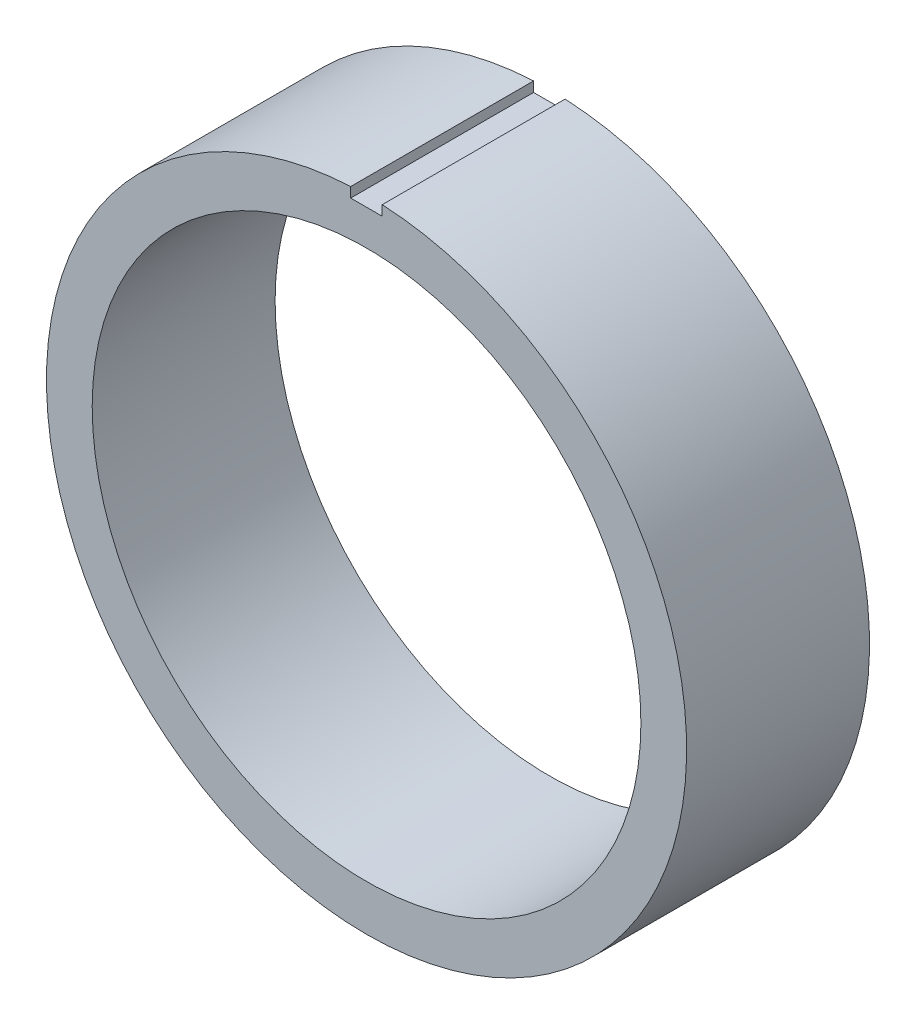
from build123d import *

# Parameters (mm, degrees)
SKETCH1_R           = 14
SKETCH1_R_2         = 12
BOSS_EXTRUDE1_DEPTH = 8
SKETCH2_W           = 1.376963526
SKETCH2_H           = 0.817572093
CUT_EXTRUDE1_DEPTH  = 10


with BuildPart() as part:
    # Sketch1 → Boss-Extrude1 (new body)
    with BuildSketch(Plane.XY):
        Circle(SKETCH1_R)
        Circle(SKETCH1_R_2, mode=Mode.SUBTRACT)
    extrude(amount=BOSS_EXTRUDE1_DEPTH)

    # Sketch2 → Cut-Extrude1 (cut)
    with BuildSketch(Plane.XY.offset(8)):
        with Locations((-0.004197142, 13.953537254)):
            Rectangle(SKETCH2_W, SKETCH2_H)
    extrude(amount=-CUT_EXTRUDE1_DEPTH, mode=Mode.SUBTRACT)


solid = part.part
